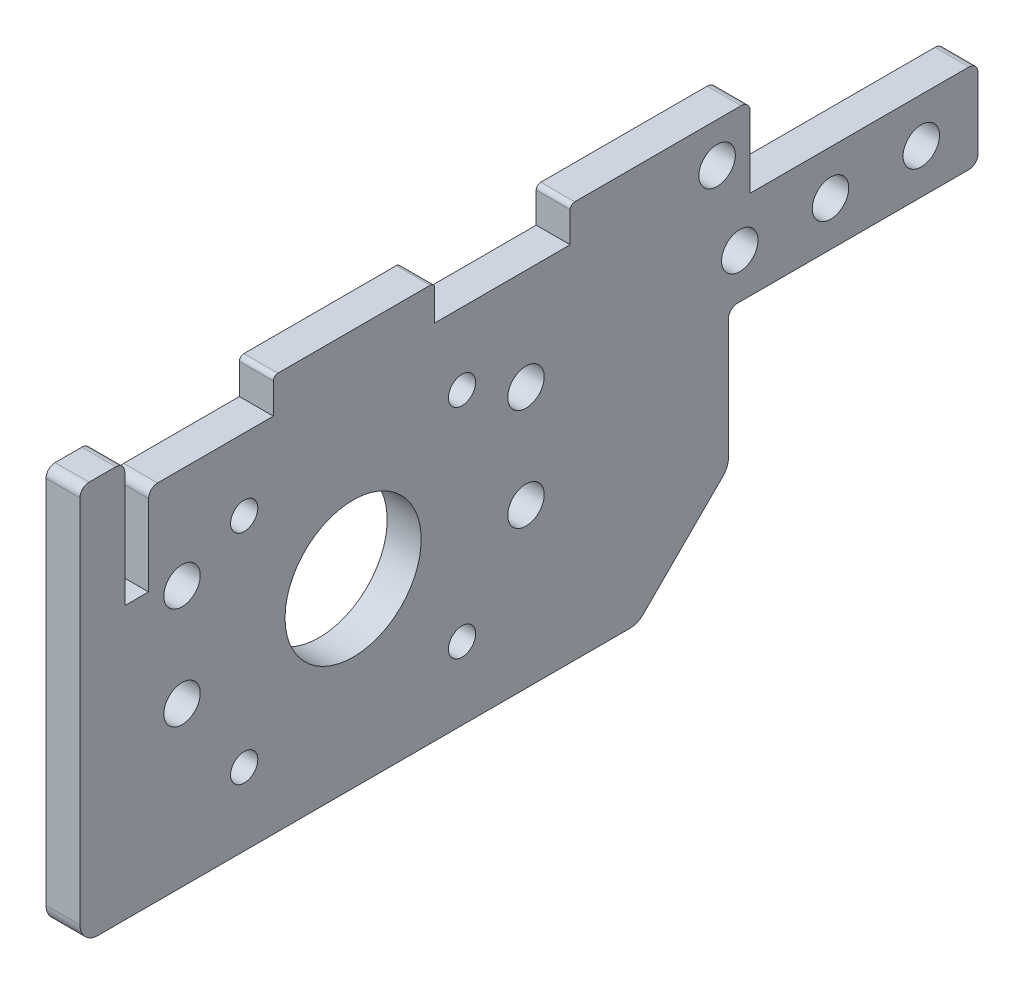
from build123d import *

# Parameters (mm, degrees)
SKETCH6_R                   = 9.525
SKETCH6_R_2                 = 1.905
SKETCH6_R_3                 = 2.5527
SIDE_PLATE_EXTRUDE_DEPTH    = 4.7498
SKETCH15_R                  = 2.5527
CUSTOM_NUTSTRIP_HOLES_DEPTH = 5.7498
SKETCH43_W                  = 3.175
SKETCH43_H                  = 12.7
CUT_EXTRUDE19_DEPTH         = 5.7498
SKETCH73_W                  = 15.875
SKETCH73_H                  = 4.7625
SKETCH73_W_2                = 22.733
SKETCH73_W_3                = 6.35
BOSS_EXTRUDE28_DEPTH        = 4.7498
SKETCH108_W                 = 9.525
SKETCH108_H                 = 11.1125
SKETCH108_R                 = 2.5527
BOSS_EXTRUDE35_DEPTH        = 4.7498
SKETCH90_W                  = 18.959213894
SKETCH90_H                  = 4.8895
SKETCH90_W_2                = 34.925
SKETCH90_H_2                = 31.877
SIDE_PLATE_TOLERENCES_DEPTH = 5.7498
CHAMFER8_SIZE               = 12.7
FILLET15_R                  = 2.54
FILLET26_R                  = 1.27
FILLET29_R                  = 0.635


with BuildPart() as part:
    # Sketch6 → Side Plate Extrude (new body)
    with BuildSketch(Plane.ZY.offset(104.775)):
        Polygon((162.052, -25.4), (162.052, 25.4), (77.649686106, 25.4), (77.649686106, 19.05), (36.374686106, 19.05), (36.374686106, 6.35), (71.299686106, 6.35), (71.299686106, -25.4), align=None)
        with Locations((123.825, 0)):
            Circle(SKETCH6_R, mode=Mode.SUBTRACT)
        with Locations((108.585, -15.24)):
            Circle(SKETCH6_R_2, mode=Mode.SUBTRACT)
        with Locations((108.585, 15.24)):
            Circle(SKETCH6_R_2, mode=Mode.SUBTRACT)
        with Locations((139.065, 15.24)):
            Circle(SKETCH6_R_2, mode=Mode.SUBTRACT)
        with Locations((139.065, -15.24)):
            Circle(SKETCH6_R_2, mode=Mode.SUBTRACT)
        with Locations((147.7645, 11.1125)):
            Circle(SKETCH6_R_3, mode=Mode.SUBTRACT)
        with Locations((99.6315, 11.1125)):
            Circle(SKETCH6_R_3, mode=Mode.SUBTRACT)
        with Locations((99.6315, -3.175)):
            Circle(SKETCH6_R_3, mode=Mode.SUBTRACT)
        with Locations((147.7645, -3.175)):
            Circle(SKETCH6_R_3, mode=Mode.SUBTRACT)
    extrude(amount=SIDE_PLATE_EXTRUDE_DEPTH)

    # Sketch15 → Custom Nutstrip Holes (cut, through all)
    with BuildSketch(Plane.ZY.offset(109.5248)):
        with Locations((44.312186106, 12.7)):
            Circle(SKETCH15_R)
        with Locations((57.012186106, 12.7)):
            Circle(SKETCH15_R)
        with Locations((69.712186106, 12.7)):
            Circle(SKETCH15_R)
    extrude(amount=-CUSTOM_NUTSTRIP_HOLES_DEPTH, mode=Mode.SUBTRACT)

    # Sketch43 → Cut-Extrude19 (cut, through all)
    with BuildSketch(Plane.ZY.offset(109.5248)):
        with Locations((154.1145, 19.05)):
            Rectangle(SKETCH43_W, SKETCH43_H)
    extrude(amount=-CUT_EXTRUDE19_DEPTH, mode=Mode.SUBTRACT)

    # Sketch73 → Boss-Extrude28 (add, through all)
    with BuildSketch(Plane.ZY.offset(109.5248)):
        with Locations((85.587186106, 27.78125)):
            Rectangle(SKETCH73_W, SKETCH73_H)
        with Locations((123.698, 27.78125)):
            Rectangle(SKETCH73_W_2, SKETCH73_H)
        with Locations((158.877, 27.78125)):
            Rectangle(SKETCH73_W_3, SKETCH73_H)
    extrude(amount=-BOSS_EXTRUDE28_DEPTH)

    # Sketch108 → Boss-Extrude35 (add, through all)
    with BuildSketch(Plane(origin=(-104.775, 0, 0), x_dir=(0, 0, -1), z_dir=(1, 0, 0))):
        with Locations((-72.887186106, 24.60625)):
            Rectangle(SKETCH108_W, SKETCH108_H)
        with Locations((-72.887186106, 24.60625)):
            Circle(SKETCH108_R, mode=Mode.SUBTRACT)
    extrude(amount=-BOSS_EXTRUDE35_DEPTH)

    # Sketch90 → Side Plate Tolerences (cut, through all)
    with BuildSketch(Plane(origin=(-104.775, 0, 0), x_dir=(0, 0, -1), z_dir=(1, 0, 0))):
        Polygon((-152.4508, 12.7), (-155.7782, 12.7), (-155.7782, 30.1625), (-152.4508, 30.1625), (-134.9883, 30.1625), (-134.9883, 25.273), (-152.4508, 25.273), align=None)
        with Locations((-102.928093053, 27.71775)):
            Rectangle(SKETCH90_W, SKETCH90_H)
        Polygon((-68.124686106, 19.05), (-36.374686106, 19.05), (-36.374686106, 18.923), (-68.124686106, 18.923), (-68.251686106, 18.923), (-68.251686106, 30.1625), (-68.124686106, 30.1625), align=None)
        with Locations((-53.837186106, -9.4615)):
            Rectangle(SKETCH90_W_2, SKETCH90_H_2)
    extrude(amount=-SIDE_PLATE_TOLERENCES_DEPTH, mode=Mode.SUBTRACT)

    # Chamfer8
    chamfer8_edges = [part.edges().sort_by_distance(p)[0] for p in [
        (-107.1499, -25.4, 71.299686106),
    ]]
    chamfer(chamfer8_edges, length=CHAMFER8_SIZE)

    # Fillet15
    fillet15_edges = [part.edges().sort_by_distance(p)[0] for p in [
        (-107.1499, -25.4, 162.052),
        (-107.1499, -25.4, 83.999686106),
        (-107.1499, -12.7, 71.299686106),
    ]]
    fillet(fillet15_edges, radius=FILLET15_R)

    # Fillet26
    fillet26_edges = [part.edges().sort_by_distance(p)[0] for p in [
        (-107.1499, 30.1625, 162.052),
        (-107.1499, 30.1625, 155.7782),
        (-107.1499, 25.273, 152.4508),
        (-107.1499, 18.923, 36.374686106),
        (-107.1499, 30.1625, 68.251686106),
        (-107.1499, 6.477, 36.374686106),
        (-107.1499, 6.477, 71.299686106),
    ]]
    fillet(fillet26_edges, radius=FILLET26_R)

    # Fillet29
    fillet29_edges = [part.edges().sort_by_distance(p)[0] for p in [
        (-107.1499, 30.1625, 134.9883),
        (-107.1499, 30.1625, 112.4077),
        (-107.1499, 30.1625, 93.448486106),
    ]]
    fillet(fillet29_edges, radius=FILLET29_R)


solid = part.part
